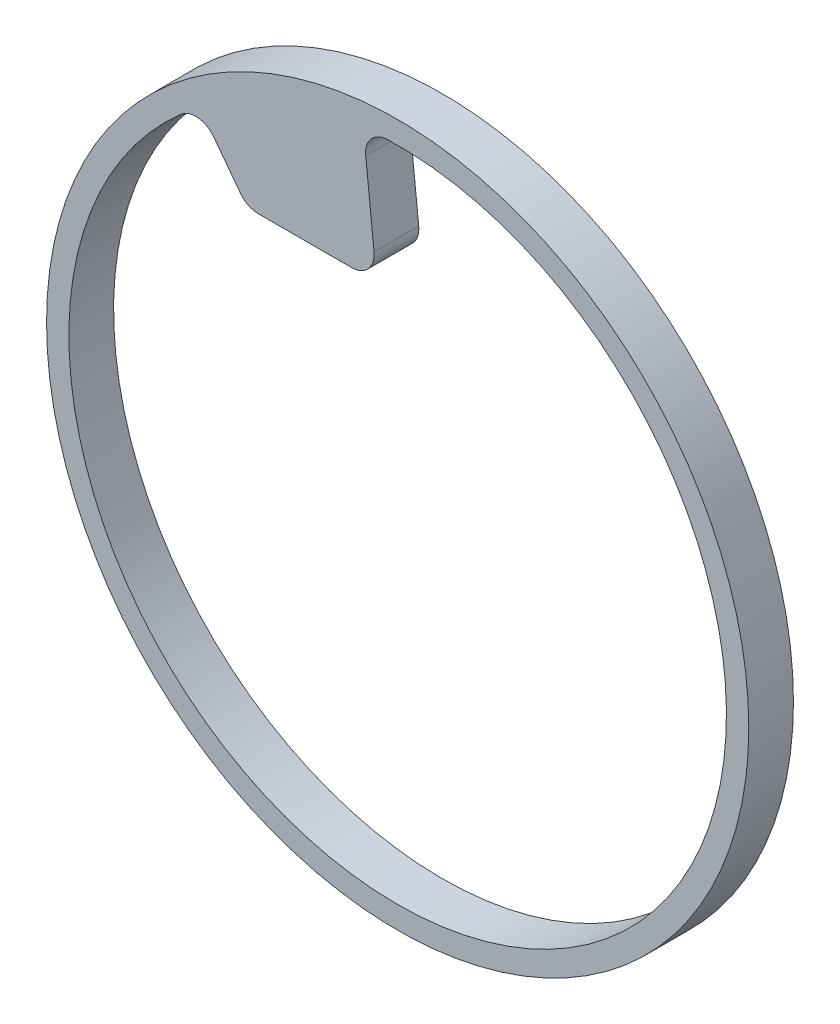
from build123d import *

# Parameters (mm, degrees)
SKETCH1_R           = 24.9555
SKETCH1_R_2         = 23.368
BOSS_EXTRUDE1_DEPTH = 3.175
BOSS_EXTRUDE2_DEPTH = 3.175
FILLET1_R           = 1.6002


with BuildPart() as part:
    # Sketch1 → Boss-Extrude1 (new body)
    with BuildSketch(Plane.XY):
        Circle(SKETCH1_R)
        Circle(SKETCH1_R_2, mode=Mode.SUBTRACT)
    extrude(amount=BOSS_EXTRUDE1_DEPTH)

    # Sketch2 → Boss-Extrude2 (add, through all)
    with BuildSketch(Plane.XY.offset(3.175)):
        with BuildLine():
            Line((-14.063213461, 18.662514599), (-10.700271112, 14.199739369))
            Line((-10.700271112, 14.199739369), (-1.492452747, 14.199739369))
            Line((-1.492452747, 14.199739369), (-2.44262113, 23.239987651))
            ThreePointArc((-2.44262113, 23.239987651), (-8.564400666, 21.741997729), (-14.063213461, 18.662514599))
        make_face()
    extrude(amount=-BOSS_EXTRUDE2_DEPTH)

    # Fillet1
    fillet1_edges = [part.edges().sort_by_distance(p)[0] for p in [
        (-14.063213461, 18.662514599, 1.5875),
        (-2.44262113, 23.239987651, 1.5875),
        (-1.492452747, 14.199739369, 1.5875),
        (-10.700271112, 14.199739369, 1.5875),
    ]]
    fillet(fillet1_edges, radius=FILLET1_R)


solid = part.part
